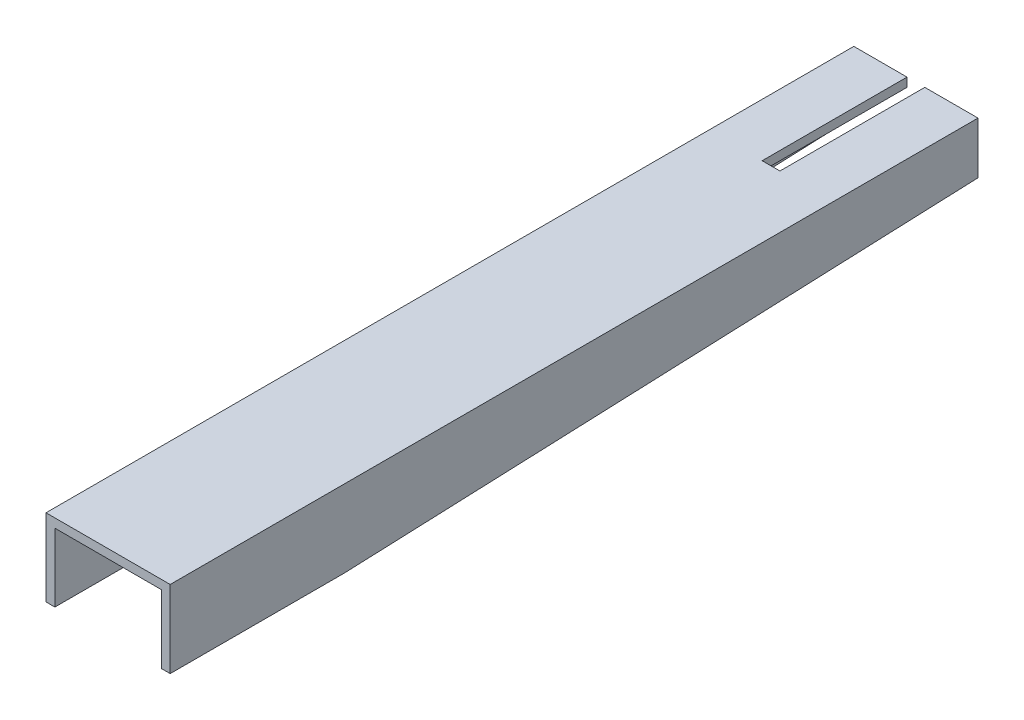
from build123d import *

# Parameters (mm, degrees)
BOSS_EXTRUDE1_DEPTH = 390.3
BOSS_EXTRUDE2_DEPTH = 4.3
SKETCH3_W           = 8.6
SKETCH3_H           = 70
CUT_EXTRUDE1_DEPTH  = 10


with BuildPart() as part:
    # Sketch1 → Boss-Extrude1 (new body)
    with BuildSketch(Plane.XY):
        Polygon((-30, 0), (-25.7, 0), (-25.7, 20.7), (25.7, 20.7), (25.7, 0), (30, 0), (30, 25), (-30, 25), align=None)
    extrude(amount=BOSS_EXTRUDE1_DEPTH)

    # Sketch2 → Boss-Extrude2 (add)
    with BuildSketch(Plane(origin=(30, 0, 0), x_dir=(0, 0, -1), z_dir=(1, 0, 0))):
        Polygon((-306, -12.31), (0, 0), (-390.3, 0), (-390.3, -12.31), align=None)
    boss_extrude2 = extrude(amount=-BOSS_EXTRUDE2_DEPTH)

    # Mirror1: Boss-Extrude2 across plane
    add(boss_extrude2.mirror(Plane(origin=(0, 0, 0), x_dir=(0, 0, 1), z_dir=(1, 0, 0))))

    # Sketch3 → Cut-Extrude1 (cut)
    with BuildSketch(Plane(origin=(0, 25, 0), x_dir=(1, 0, 0), z_dir=(0, 1, 0))):
        with Locations((0, -35)):
            Rectangle(SKETCH3_W, SKETCH3_H)
    extrude(amount=-CUT_EXTRUDE1_DEPTH, mode=Mode.SUBTRACT)


solid = part.part
